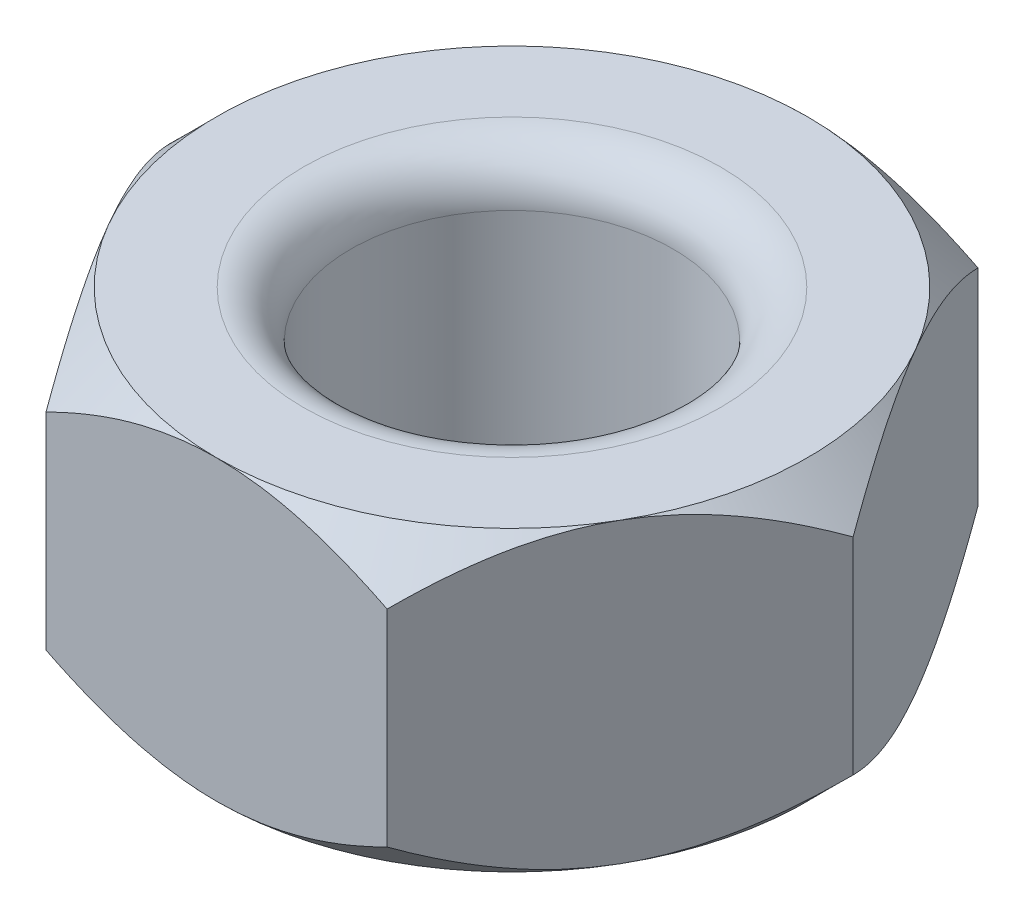
from build123d import *

# Parameters (mm, degrees)
EXTRUDE_1_DEPTH     = 6.28
SKETCH_2_OUTSIDE_W  = 22.412
SKETCH_2_OUTSIDE_H  = 20.482
SKETCH_2_OUTSIDE_R  = 6.235382907
CUT_EXTRUDE_2_DEPTH = 1
CUT_EXTRUDE_2_DRAFT = -45
SKETCH_3_OUTSIDE_W  = 22.412
SKETCH_3_OUTSIDE_H  = 20.482
SKETCH_3_OUTSIDE_R  = 6.235382907
CUT_EXTRUDE_3_DEPTH = 1
CUT_EXTRUDE_3_DRAFT = -45
SKETCH_4_R          = 3.4
CUT_EXTRUDE_4_DEPTH = 7.28
FILLET_1_R          = 1
FILLET_2_R          = 1


with BuildPart() as part:
    # Эскиз1 → Бобышка-Вытянуть1 (new body)
    with BuildSketch(Plane(origin=(0, 0, 0), x_dir=(1, 0, 0), z_dir=(0, 1, 0))):
        Polygon((7.2, 0), (3.6, 6.235382907), (-3.6, 6.235382907), (-7.2, 0), (-3.6, -6.235382907), (3.6, -6.235382907), align=None)
    extrude(amount=EXTRUDE_1_DEPTH)


with BuildPart() as cut_extrude_2_tool:
    # Эскиз2 outside → Вырез-Вытянуть2 (with draft: the straight prism first)
    with BuildSketch(Plane(origin=(0, 6.28, 0), x_dir=(1, 0, 0), z_dir=(0, 1, 0))):
        Rectangle(SKETCH_2_OUTSIDE_W, SKETCH_2_OUTSIDE_H)
        Circle(SKETCH_2_OUTSIDE_R, mode=Mode.SUBTRACT)
    extrude(amount=-CUT_EXTRUDE_2_DEPTH)
    # Вырез-Вытянуть2: the draft: its side faces are tilted about the plane it starts from
    cut_extrude_2_sides = [cut_extrude_2_tool.faces().sort_by_distance(p)[0] for p in [
        (0, 5.78, 10.241),
        (11.206, 5.78, 0),
        (0, 5.78, -10.241),
        (-11.206, 5.78, 0),
        (-6.235382907, 5.78, 0),
    ]]
    draft(cut_extrude_2_sides, Plane(origin=(0, 6.28, 0), x_dir=(1, 0, 0), z_dir=(0, 1, 0)), CUT_EXTRUDE_2_DRAFT)


with BuildPart() as part_1:
    add(part.part)

    # Вырез-Вытянуть2: cut by cut_extrude_2_tool
    add(cut_extrude_2_tool.part, mode=Mode.SUBTRACT)


with BuildPart() as cut_extrude_3_tool:
    # Эскиз3 outside → Вырез-Вытянуть3 (with draft: the straight prism first)
    with BuildSketch(Plane.XZ):
        Rectangle(SKETCH_3_OUTSIDE_W, SKETCH_3_OUTSIDE_H)
        Circle(SKETCH_3_OUTSIDE_R, mode=Mode.SUBTRACT)
    extrude(amount=-CUT_EXTRUDE_3_DEPTH)
    # Вырез-Вытянуть3: the draft: its side faces are tilted about the plane it starts from
    cut_extrude_3_sides = [cut_extrude_3_tool.faces().sort_by_distance(p)[0] for p in [
        (0, 0.5, -10.241),
        (11.206, 0.5, 0),
        (0, 0.5, 10.241),
        (-11.206, 0.5, 0),
        (-6.235382907, 0.5, 0),
    ]]
    draft(cut_extrude_3_sides, Plane.XZ, CUT_EXTRUDE_3_DRAFT)


with BuildPart() as part_2:
    add(part_1.part)

    # Вырез-Вытянуть3: cut by cut_extrude_3_tool
    add(cut_extrude_3_tool.part, mode=Mode.SUBTRACT)

    # Эскиз4 → Вырез-Вытянуть4 (cut, through all)
    with BuildSketch(Plane(origin=(0, 6.28, 0), x_dir=(1, 0, 0), z_dir=(0, 1, 0))):
        with Locations(Location((0, 0, 0), (0, 0, 270))):  # turned: the seam where the file's is
            Circle(SKETCH_4_R)
    extrude(amount=-CUT_EXTRUDE_4_DEPTH, mode=Mode.SUBTRACT)

    # Скругление1
    fillet_1_edges = [part_2.edges().sort_by_distance(p)[0] for p in [
        (0, 6.28, -3.4),
    ]]
    fillet(fillet_1_edges, radius=FILLET_1_R)

    # Скругление2
    fillet_2_edges = [part_2.edges().sort_by_distance(p)[0] for p in [
        (0, 0, -3.4),
    ]]
    fillet(fillet_2_edges, radius=FILLET_2_R)


solid = part_2.part
